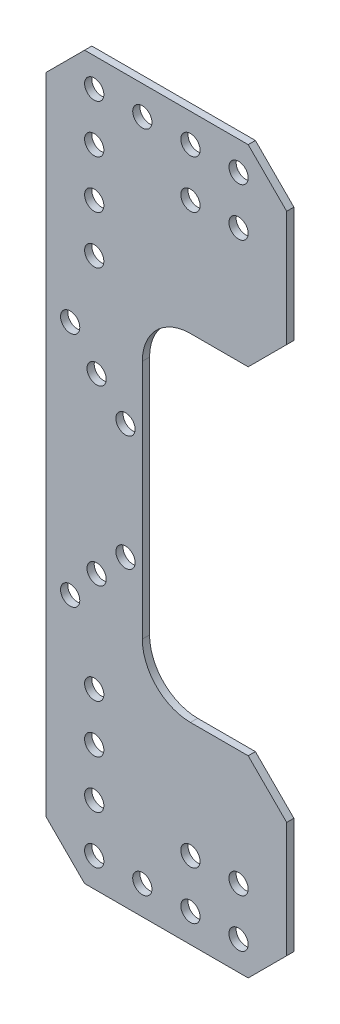
from build123d import *

# Parameters (mm, degrees)
SKETCH1_W           = 20
SKETCH1_H           = 70
SKETCH1_R           = 2
BOSS_EXTRUDE1_DEPTH = 1.5
SKETCH2_W           = 50
SKETCH2_H           = 40
BOSS_EXTRUDE2_DEPTH = 1.5
SKETCH3_R           = 2
CUT_EXTRUDE1_DEPTH  = 10
CHAMFER1_SIZE       = 8
FILLET1_R           = 10


with BuildPart() as part:
    # Sketch1 → Boss-Extrude1 (new body)
    with BuildSketch(Plane.XY):
        with Locations((-15.5, 0)):
            Rectangle(SKETCH1_W, SKETCH1_H)
        with Locations((-9, -12)):
            Circle(SKETCH1_R, mode=Mode.SUBTRACT)
        with Locations((-9, 12)):
            Circle(SKETCH1_R, mode=Mode.SUBTRACT)
        with Locations((-15, -18)):
            Circle(SKETCH1_R, mode=Mode.SUBTRACT)
        with Locations((-15, 18)):
            Circle(SKETCH1_R, mode=Mode.SUBTRACT)
        with Locations((-20.5, -24.571324751)):
            Circle(SKETCH1_R, mode=Mode.SUBTRACT)
        with Locations((-20.5, 24.571324751)):
            Circle(SKETCH1_R, mode=Mode.SUBTRACT)
    extrude(amount=BOSS_EXTRUDE1_DEPTH)

    # Sketch2 → Boss-Extrude2 (add)
    with BuildSketch(Plane.XY.offset(1.5)):
        with Locations((-0.5, -55)):
            Rectangle(SKETCH2_W, SKETCH2_H)
    boss_extrude2 = extrude(amount=-BOSS_EXTRUDE2_DEPTH)

    # Sketch3 → Cut-Extrude1 (cut)
    with BuildSketch(Plane.XY.offset(1.5)):
        with Locations((14.5, -69)):
            Circle(SKETCH3_R)
        with Locations((4.5, -69)):
            Circle(SKETCH3_R)
        with Locations((-5.5, -69)):
            Circle(SKETCH3_R)
        with Locations((-15.5, -69)):
            Circle(SKETCH3_R)
        with Locations((4.5, -59)):
            Circle(SKETCH3_R)
        with Locations((14.5, -59)):
            Circle(SKETCH3_R)
        with Locations((-15.5, -59)):
            Circle(SKETCH3_R)
        with Locations((-15.5, -49)):
            Circle(SKETCH3_R)
        with Locations((-15.5, -39)):
            Circle(SKETCH3_R)
    cut_extrude1 = extrude(amount=-CUT_EXTRUDE1_DEPTH, mode=Mode.SUBTRACT)

    # Mirror1: Boss-Extrude2, Cut-Extrude1 across plane
    add(boss_extrude2.mirror(Plane.ZX))
    add(cut_extrude1.mirror(Plane.ZX), mode=Mode.SUBTRACT)

    # Chamfer1
    chamfer1_edges = [part.edges().sort_by_distance(p)[0] for p in [
        (24.5, -75, 0.75),
        (24.5, -35, 0.75),
        (-25.5, -75, 0.75),
        (24.5, 35, 0.75),
        (-25.5, 75, 0.75),
        (24.5, 75, 0.75),
    ]]
    chamfer(chamfer1_edges, length=CHAMFER1_SIZE)

    # Fillet1
    fillet1_edges = [part.edges().sort_by_distance(p)[0] for p in [
        (-5.5, 35, 0.75),
        (-5.5, -35, 0.75),
    ]]
    fillet(fillet1_edges, radius=FILLET1_R)


solid = part.part
